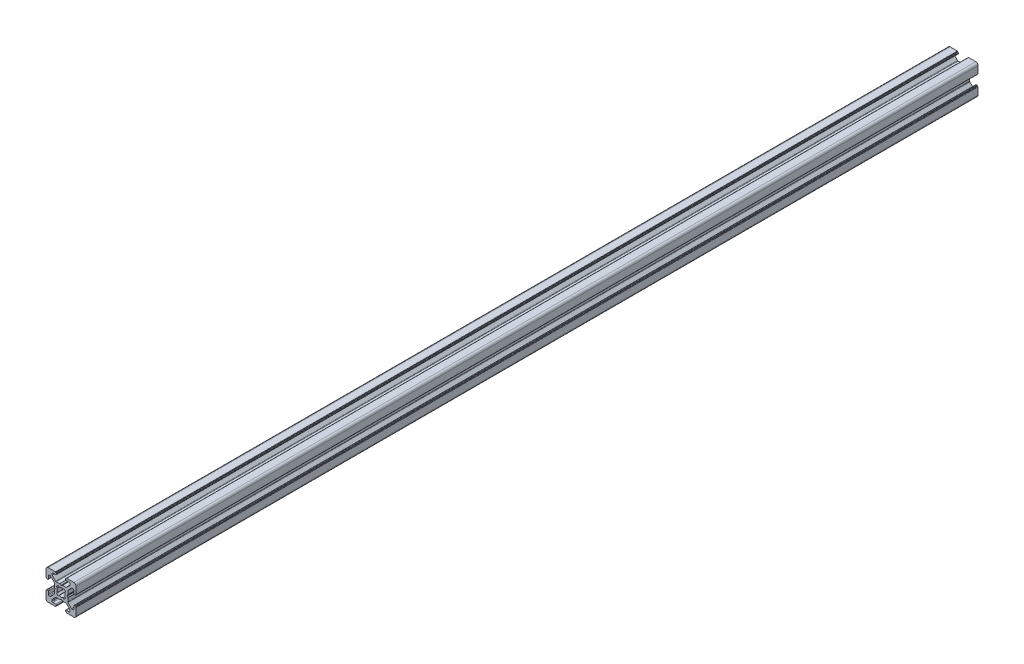
from build123d import *

# Parameters (mm, degrees)
EXTRUDE1_DEPTH = 600


with BuildPart() as part:
    # Sketch1 → Extrude1 (new body)
    with BuildSketch(Plane.XY):
        with BuildLine():
            Line((-3.5, 8.499999673), (-5.500000686, 8.499999673))
            ThreePointArc((-5.500000686, 8.499999673), (-5.853554077, 8.353553064), (-6.000000686, 7.999999673))
            Line((-6.000000686, 7.999999673), (-6.000000686, 7.267766626))
            ThreePointArc((-6.000000686, 7.267766626), (-5.961940448, 7.076424899), (-5.853554059, 6.914213219))
            Line((-5.853554059, 6.914213219), (-3.585787212, 4.646446592))
            ThreePointArc((-3.585787212, 4.646446592), (-3.423575544, 4.538060229), (-3.232233839, 4.5))
            Line((-3.232233839, 4.5), (-0.953590312, 4.5))
            ThreePointArc((-0.953590312, 4.5), (-0.901826505, 4.493185166), (-0.853590316, 4.473205083))
            Line((-0.853590316, 4.473205083), (-0.100000045, 4.038119562))
            ThreePointArc((-0.100000045, 4.038119562), (0, 4.011324632), (0.100000045, 4.038119562))
            Line((0.100000045, 4.038119562), (0.853590316, 4.473205083))
            ThreePointArc((0.853590316, 4.473205083), (0.901826505, 4.493185166), (0.953590312, 4.5))
            Line((0.953590312, 4.5), (3.232233839, 4.5))
            ThreePointArc((3.232233839, 4.5), (3.423575544, 4.538060229), (3.585787212, 4.646446592))
            Line((3.585787212, 4.646446592), (5.853554059, 6.914213219))
            ThreePointArc((5.853554059, 6.914213219), (5.961940448, 7.076424899), (6.000000686, 7.267766626))
            Line((6.000000686, 7.267766626), (6.000000686, 7.999999673))
            ThreePointArc((6.000000686, 7.999999673), (5.853554077, 8.353553064), (5.500000686, 8.499999673))
            Line((5.500000686, 8.499999673), (3.5, 8.499999673))
            ThreePointArc((3.5, 8.499999673), (3.146446609, 8.646446283), (3, 8.999999673))
            Line((3, 8.999999673), (3, 9.3))
            ThreePointArc((3, 9.3), (3.058578644, 9.441421356), (3.2, 9.5))
            Line((3.2, 9.5), (3.350000228, 9.5))
            ThreePointArc((3.350000228, 9.5), (3.491421584, 9.558578644), (3.550000228, 9.7))
            Line((3.550000228, 9.7), (3.550000228, 9.8))
            ThreePointArc((3.550000228, 9.8), (3.608578871, 9.941421356), (3.750000228, 10))
            Line((3.750000228, 10), (8.5, 10))
            ThreePointArc((8.5, 10), (9.560660172, 9.560660172), (10, 8.5))
            Line((10, 8.5), (10, 3.749999605))
            ThreePointArc((10, 3.749999605), (9.941421356, 3.608578248), (9.8, 3.549999605))
            Line((9.8, 3.549999605), (9.699999732, 3.549999605))
            ThreePointArc((9.699999732, 3.549999605), (9.558578376, 3.491420961), (9.499999732, 3.349999605))
            Line((9.499999732, 3.349999605), (9.499999732, 3.2))
            ThreePointArc((9.499999732, 3.2), (9.441421088, 3.058578644), (9.299999732, 3))
            Line((9.299999732, 3), (8.999999732, 3))
            ThreePointArc((8.999999732, 3), (8.646446341, 3.146446609), (8.499999732, 3.5))
            Line((8.499999732, 3.5), (8.499999732, 5.499999605))
            ThreePointArc((8.499999732, 5.499999605), (8.353553123, 5.853552995), (7.999999732, 5.999999605))
            Line((7.999999732, 5.999999605), (7.267766685, 5.999999605))
            ThreePointArc((7.267766685, 5.999999605), (7.076424969, 5.961939371), (6.914213294, 5.853552995))
            Line((6.914213294, 5.853552995), (4.646446398, 3.585786099))
            ThreePointArc((4.646446398, 3.585786099), (4.538060023, 3.423574425), (4.499999789, 3.232232708))
            Line((4.499999789, 3.232232708), (4.499999789, 0.953589302))
            ThreePointArc((4.499999789, 0.953589302), (4.493184953, 0.90182549), (4.473204867, 0.853589297))
            Line((4.473204867, 0.853589297), (4.038119841, 0.099999969))
            ThreePointArc((4.038119841, 0.099999969), (4.011324929, 0), (4.038119841, -0.099999969))
            Line((4.038119841, -0.099999969), (4.473204867, -0.853589297))
            ThreePointArc((4.473204867, -0.853589297), (4.493184953, -0.90182549), (4.499999789, -0.953589302))
            Line((4.499999789, -0.953589302), (4.499999789, -3.232232708))
            ThreePointArc((4.499999789, -3.232232708), (4.538060023, -3.423574425), (4.646446398, -3.585786099))
            Line((4.646446398, -3.585786099), (6.914213294, -5.853552995))
            ThreePointArc((6.914213294, -5.853552995), (7.076424969, -5.961939371), (7.267766685, -5.999999605))
            Line((7.267766685, -5.999999605), (7.999999732, -5.999999605))
            ThreePointArc((7.999999732, -5.999999605), (8.353553123, -5.853552995), (8.499999732, -5.499999605))
            Line((8.499999732, -5.499999605), (8.499999732, -3.5))
            ThreePointArc((8.499999732, -3.5), (8.646446341, -3.146446609), (8.999999732, -3))
            Line((8.999999732, -3), (9.299999732, -3))
            ThreePointArc((9.299999732, -3), (9.441421088, -3.058578644), (9.499999732, -3.2))
            Line((9.499999732, -3.2), (9.499999732, -3.349999605))
            ThreePointArc((9.499999732, -3.349999605), (9.558578376, -3.491420961), (9.699999732, -3.549999605))
            Line((9.699999732, -3.549999605), (9.8, -3.549999605))
            ThreePointArc((9.8, -3.549999605), (9.941421356, -3.608578248), (10, -3.749999605))
            Line((10, -3.749999605), (10, -8.5))
            ThreePointArc((10, -8.5), (9.560660172, -9.560660172), (8.5, -10))
            Line((8.5, -10), (3.750000228, -10))
            ThreePointArc((3.750000228, -10), (3.608578871, -9.941421356), (3.550000228, -9.8))
            Line((3.550000228, -9.8), (3.550000228, -9.7))
            ThreePointArc((3.550000228, -9.7), (3.491421584, -9.558578644), (3.350000228, -9.5))
            Line((3.350000228, -9.5), (3.2, -9.5))
            ThreePointArc((3.2, -9.5), (3.058578644, -9.441421356), (3, -9.3))
            Line((3, -9.3), (3, -8.999999673))
            ThreePointArc((3, -8.999999673), (3.146446609, -8.646446283), (3.5, -8.499999673))
            Line((3.5, -8.499999673), (5.500000686, -8.499999673))
            ThreePointArc((5.500000686, -8.499999673), (5.853554077, -8.353553064), (6.000000686, -7.999999673))
            Line((6.000000686, -7.999999673), (6.000000686, -7.267766626))
            ThreePointArc((6.000000686, -7.267766626), (5.961940448, -7.076424899), (5.853554059, -6.914213219))
            Line((5.853554059, -6.914213219), (3.585787212, -4.646446592))
            ThreePointArc((3.585787212, -4.646446592), (3.423575544, -4.538060229), (3.232233839, -4.5))
            Line((3.232233839, -4.5), (0.953590312, -4.5))
            ThreePointArc((0.953590312, -4.5), (0.901826505, -4.493185166), (0.853590316, -4.473205083))
            Line((0.853590316, -4.473205083), (0.100000045, -4.038119562))
            ThreePointArc((0.100000045, -4.038119562), (0, -4.011324632), (-0.100000045, -4.038119562))
            Line((-0.100000045, -4.038119562), (-0.853590316, -4.473205083))
            ThreePointArc((-0.853590316, -4.473205083), (-0.901826505, -4.493185166), (-0.953590312, -4.5))
            Line((-0.953590312, -4.5), (-3.232233839, -4.5))
            ThreePointArc((-3.232233839, -4.5), (-3.423575544, -4.538060229), (-3.585787212, -4.646446592))
            Line((-3.585787212, -4.646446592), (-5.853554059, -6.914213219))
            ThreePointArc((-5.853554059, -6.914213219), (-5.961940448, -7.076424899), (-6.000000686, -7.267766626))
            Line((-6.000000686, -7.267766626), (-6.000000686, -7.999999673))
            ThreePointArc((-6.000000686, -7.999999673), (-5.853554077, -8.353553064), (-5.500000686, -8.499999673))
            Line((-5.500000686, -8.499999673), (-3.5, -8.499999673))
            ThreePointArc((-3.5, -8.499999673), (-3.146446609, -8.646446283), (-3, -8.999999673))
            Line((-3, -8.999999673), (-3, -9.3))
            ThreePointArc((-3, -9.3), (-3.058578644, -9.441421356), (-3.2, -9.5))
            Line((-3.2, -9.5), (-3.350000228, -9.5))
            ThreePointArc((-3.350000228, -9.5), (-3.491421584, -9.558578644), (-3.550000228, -9.7))
            Line((-3.550000228, -9.7), (-3.550000228, -9.8))
            ThreePointArc((-3.550000228, -9.8), (-3.608578871, -9.941421356), (-3.750000228, -10))
            Line((-3.750000228, -10), (-8.5, -10))
            ThreePointArc((-8.5, -10), (-9.560660172, -9.560660172), (-10, -8.5))
            Line((-10, -8.5), (-10, -3.749999605))
            ThreePointArc((-10, -3.749999605), (-9.941421356, -3.608578248), (-9.8, -3.549999605))
            Line((-9.8, -3.549999605), (-9.699999732, -3.549999605))
            ThreePointArc((-9.699999732, -3.549999605), (-9.558578376, -3.491420961), (-9.499999732, -3.349999605))
            Line((-9.499999732, -3.349999605), (-9.499999732, -3.2))
            ThreePointArc((-9.499999732, -3.2), (-9.441421088, -3.058578644), (-9.299999732, -3))
            Line((-9.299999732, -3), (-8.999999732, -3))
            ThreePointArc((-8.999999732, -3), (-8.646446341, -3.146446609), (-8.499999732, -3.5))
            Line((-8.499999732, -3.5), (-8.499999732, -5.499999605))
            ThreePointArc((-8.499999732, -5.499999605), (-8.353553123, -5.853552995), (-7.999999732, -5.999999605))
            Line((-7.999999732, -5.999999605), (-7.267766685, -5.999999605))
            ThreePointArc((-7.267766685, -5.999999605), (-7.076424969, -5.961939371), (-6.914213294, -5.853552995))
            Line((-6.914213294, -5.853552995), (-4.646446398, -3.585786099))
            ThreePointArc((-4.646446398, -3.585786099), (-4.538060023, -3.423574425), (-4.499999789, -3.232232708))
            Line((-4.499999789, -3.232232708), (-4.499999789, -0.953589302))
            ThreePointArc((-4.499999789, -0.953589302), (-4.493184953, -0.90182549), (-4.473204867, -0.853589297))
            Line((-4.473204867, -0.853589297), (-4.038119841, -0.099999969))
            ThreePointArc((-4.038119841, -0.099999969), (-4.011324929, 0), (-4.038119841, 0.099999969))
            Line((-4.038119841, 0.099999969), (-4.473204867, 0.853589297))
            ThreePointArc((-4.473204867, 0.853589297), (-4.493184953, 0.90182549), (-4.499999789, 0.953589302))
            Line((-4.499999789, 0.953589302), (-4.499999789, 3.232232708))
            ThreePointArc((-4.499999789, 3.232232708), (-4.538060023, 3.423574425), (-4.646446398, 3.585786099))
            Line((-4.646446398, 3.585786099), (-6.914213294, 5.853552995))
            ThreePointArc((-6.914213294, 5.853552995), (-7.076424969, 5.961939371), (-7.267766685, 5.999999605))
            Line((-7.267766685, 5.999999605), (-7.999999732, 5.999999605))
            ThreePointArc((-7.999999732, 5.999999605), (-8.353553123, 5.853552995), (-8.499999732, 5.499999605))
            Line((-8.499999732, 5.499999605), (-8.499999732, 3.5))
            ThreePointArc((-8.499999732, 3.5), (-8.646446341, 3.146446609), (-8.999999732, 3))
            Line((-8.999999732, 3), (-9.299999732, 3))
            ThreePointArc((-9.299999732, 3), (-9.441421088, 3.058578644), (-9.499999732, 3.2))
            Line((-9.499999732, 3.2), (-9.499999732, 3.349999605))
            ThreePointArc((-9.499999732, 3.349999605), (-9.558578376, 3.491420961), (-9.699999732, 3.549999605))
            Line((-9.699999732, 3.549999605), (-9.8, 3.549999605))
            ThreePointArc((-9.8, 3.549999605), (-9.941421356, 3.608578248), (-10, 3.749999605))
            Line((-10, 3.749999605), (-10, 8.5))
            ThreePointArc((-10, 8.5), (-9.560660172, 9.560660172), (-8.5, 10))
            Line((-8.5, 10), (-3.750000228, 10))
            ThreePointArc((-3.750000228, 10), (-3.608578871, 9.941421356), (-3.550000228, 9.8))
            Line((-3.550000228, 9.8), (-3.550000228, 9.7))
            ThreePointArc((-3.550000228, 9.7), (-3.491421584, 9.558578644), (-3.350000228, 9.5))
            Line((-3.350000228, 9.5), (-3.2, 9.5))
            ThreePointArc((-3.2, 9.5), (-3.058578644, 9.441421356), (-3, 9.3))
            Line((-3, 9.3), (-3, 8.999999673))
            ThreePointArc((-3, 8.999999673), (-3.146446609, 8.646446283), (-3.5, 8.499999673))
        make_face()
        with BuildLine():
            Line((-1.258185436, 2.445295362), (-1.91389502, 2.989640962))
            ThreePointArc((-1.91389502, 2.989640962), (-2.511737261, 2.508410485), (-2.992174953, 1.909930962))
            Line((-2.992174953, 1.909930962), (-2.445295423, 1.258185317))
            ThreePointArc((-2.445295423, 1.258185317), (-2.75, 0), (-2.445295423, -1.258185317))
            Line((-2.445295423, -1.258185317), (-2.992174953, -1.909930962))
            ThreePointArc((-2.992174953, -1.909930962), (-2.511737261, -2.508410485), (-1.91389502, -2.989640962))
            Line((-1.91389502, -2.989640962), (-1.258185436, -2.445295362))
            ThreePointArc((-1.258185436, -2.445295362), (0, -2.75), (1.258185436, -2.445295362))
            Line((1.258185436, -2.445295362), (1.91389502, -2.989640962))
            ThreePointArc((1.91389502, -2.989640962), (2.511737261, -2.508410485), (2.992174953, -1.909930962))
            Line((2.992174953, -1.909930962), (2.445295423, -1.258185317))
            ThreePointArc((2.445295423, -1.258185317), (2.75, 0), (2.445295423, 1.258185317))
            Line((2.445295423, 1.258185317), (2.992174953, 1.909930962))
            ThreePointArc((2.992174953, 1.909930962), (2.511737261, 2.508410485), (1.91389502, 2.989640962))
            Line((1.91389502, 2.989640962), (1.258185436, 2.445295362))
            ThreePointArc((1.258185436, 2.445295362), (0, 2.75), (-1.258185436, 2.445295362))
        make_face(mode=Mode.SUBTRACT)
    extrude(amount=EXTRUDE1_DEPTH)


solid = part.part
